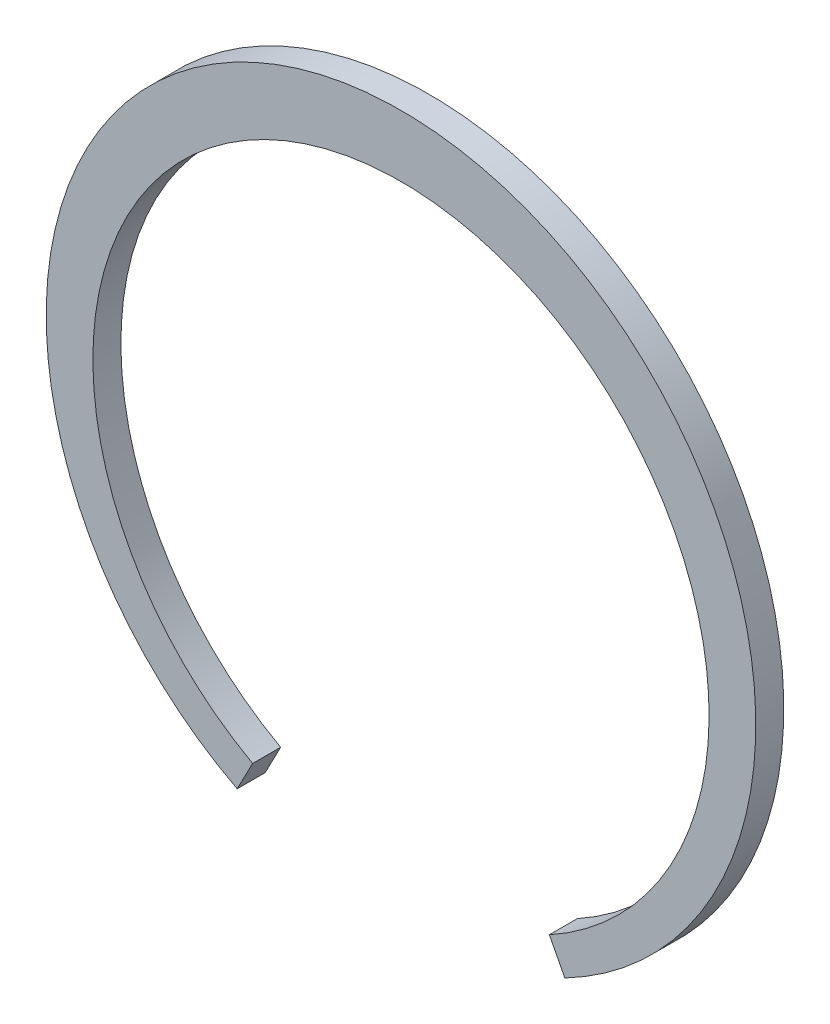
from build123d import *

# Parameters (mm, degrees)
AUFSATZ_LINEAR_AUSTRAGEN1_DEPTH = 1.5


with BuildPart() as part:
    # Skizze1 → Aufsatz-Linear austragen1 (new body)
    with BuildSketch(Plane.XY):
        with BuildLine():
            Line((-7.944603359, -15.261441058), (-8.773223651, -16.85320583))
            ThreePointArc((-8.773223651, -16.85320583), (0, 19), (8.773223651, -16.85320583))
            Line((8.773223651, -16.85320583), (7.944603359, -15.261441058))
            ThreePointArc((7.944603359, -15.261441058), (0, 15.7), (-7.944603359, -15.261441058))
        make_face()
    extrude(amount=AUFSATZ_LINEAR_AUSTRAGEN1_DEPTH)


solid = part.part
